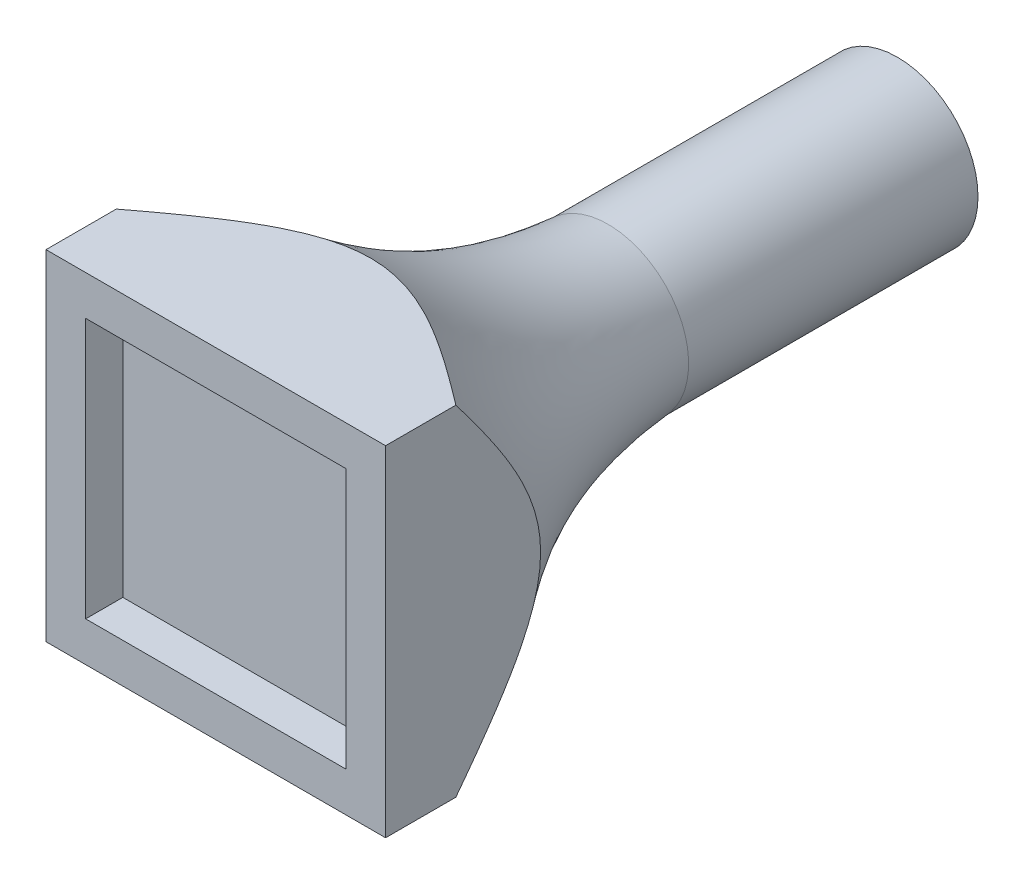
from build123d import *

# Parameters (mm, degrees)
SKETCH1_R           = 6.5
BOSS_EXTRUDE1_DEPTH = 50
SKETCH2_W           = 27.4
SKETCH2_H           = 27.4
BOSS_EXTRUDE2_DEPTH = 5
SKETCH3_W           = 21
SKETCH3_H           = 21
CUT_EXTRUDE1_DEPTH  = 3
SKETCH7_W           = 47.139349652
SKETCH7_H           = 47.139349652
SKETCH7_W_2         = 27.4
SKETCH7_H_2         = 27.4
CUT_EXTRUDE2_DEPTH  = 78
SKETCH8_R           = 2.15
CUT_EXTRUDE3_DEPTH  = 25
CUT_EXTRUDE4_DEPTH  = 3.5
SKETCH10_R          = 2.15
CUT_EXTRUDE5_DEPTH  = 15


with BuildPart() as part:
    # Sketch1 → Boss-Extrude1 (new body)
    with BuildSketch(Plane.XY):
        Circle(SKETCH1_R)
    extrude(amount=BOSS_EXTRUDE1_DEPTH)

    # Sketch2 → Boss-Extrude2 (add)
    with BuildSketch(Plane.XY.offset(50)):
        Rectangle(SKETCH2_W, SKETCH2_H)
    extrude(amount=BOSS_EXTRUDE2_DEPTH)

    # Sketch3 → Cut-Extrude1 (cut)
    with BuildSketch(Plane.XY.offset(55)):
        Rectangle(SKETCH3_W, SKETCH3_H)
    extrude(amount=-CUT_EXTRUDE1_DEPTH, mode=Mode.SUBTRACT)

    # Sketch6 → Revolve1 (revolve)
    with BuildSketch(Plane(origin=(0, 0, 0), x_dir=(0, 0, -1), z_dir=(1, 0, 0))):
        with BuildLine():
            Line((-50, 0), (-50, 20))
            add(Edge.make_bspline(
                [(-50, 20), (-32.330139343, 3.31447133), (-23.53449028, 6.5), (0, 6.5)],
                knots=[0, 0, 0, 0, 1, 1, 1, 1], degree=3))
            Line((0, 6.5), (0, 0))
            Line((0, 0), (-50, 0))
        make_face()
    revolve(axis=Axis((0, 0, 63.541170981), (0, 0, 1)))

    # Sketch7 → Cut-Extrude2 (cut)
    with BuildSketch(Plane.XY.offset(50)):
        Rectangle(SKETCH7_W, SKETCH7_H)
        Rectangle(SKETCH7_W_2, SKETCH7_H_2, mode=Mode.SUBTRACT)
    extrude(amount=-CUT_EXTRUDE2_DEPTH, mode=Mode.SUBTRACT)

    # Sketch8 → Cut-Extrude3 (cut)
    with BuildSketch(Plane(origin=(0, 0, 0), x_dir=(-1, 0, 0), z_dir=(0, 0, -1))):
        Circle(SKETCH8_R)
    extrude(amount=-CUT_EXTRUDE3_DEPTH, mode=Mode.SUBTRACT)

    # Sketch9 → Cut-Extrude4 (cut)
    with BuildSketch(Plane(origin=(0, 0, 25), x_dir=(-1, 0, 0), z_dir=(0, 0, -1))):
        Polygon((4.156921938, 0), (2.078460969, 3.6), (-2.078460969, 3.6), (-4.156921938, 0), (-2.078460969, -3.6), (2.078460969, -3.6), align=None)
    extrude(amount=-CUT_EXTRUDE4_DEPTH, mode=Mode.SUBTRACT)

    # Sketch10 → Cut-Extrude5 (cut)
    with BuildSketch(Plane(origin=(0, 0, 28.5), x_dir=(-1, 0, 0), z_dir=(0, 0, -1))):
        Circle(SKETCH10_R)
    extrude(amount=-CUT_EXTRUDE5_DEPTH, mode=Mode.SUBTRACT)


solid = part.part
